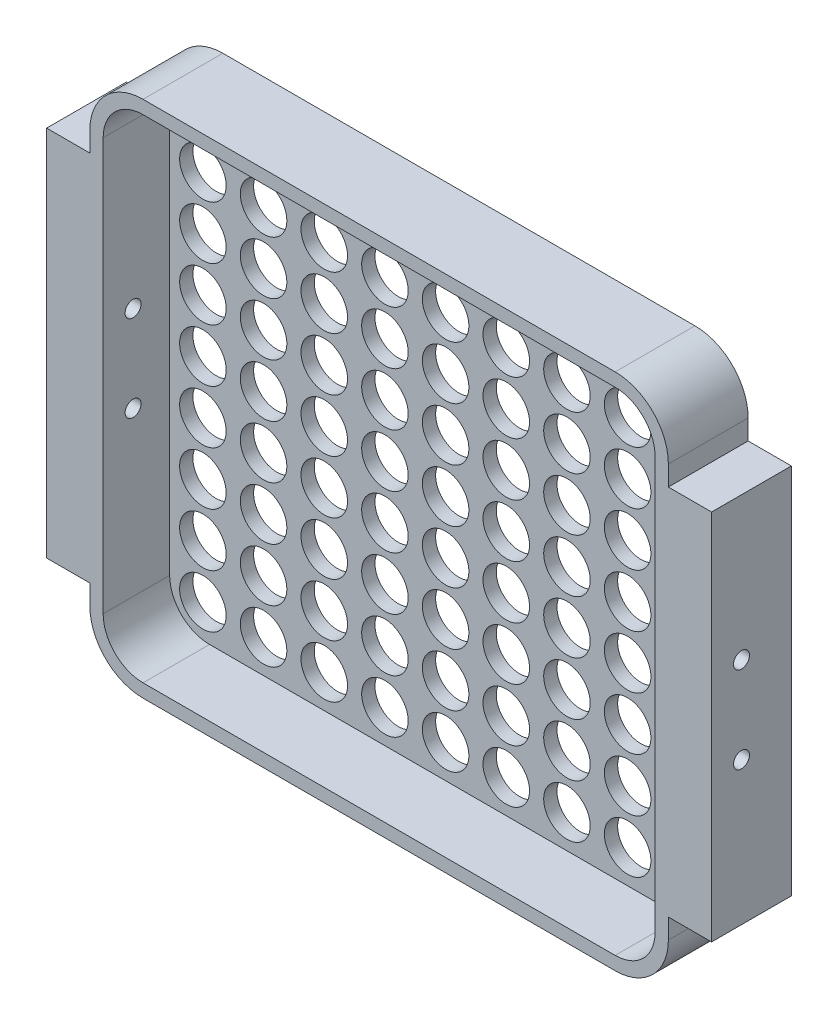
from build123d import *

# Parameters (mm, degrees)
EXTRUDE_THIN1_DEPTH       = 10
BOSS_EXTRUDE1_DEPTH       = 2
SKETCH3_W                 = 3
SKETCH3_H                 = 56
BOSS_EXTRUDE2_DEPTH       = 6.5
SKETCH4_W                 = 9
SKETCH4_H                 = 56
BOSS_EXTRUDE3_DEPTH       = 5
F_3_0MM_DOWEL_HOLE1_D     = 3
F_3_0MM_DOWEL_HOLE1_DEPTH = 150
SKETCH10_R                = 3.5
CUT_EXTRUDE1_DEPTH        = 65.195015383
CUT_EXTRUDE1_DEPTH_BACK   = 65.195015383
BOSS_EXTRUDE4_REACH       = 105.179
SKETCH12_W                = 9
SKETCH12_H                = 56
SKETCH12_R                = 1.5
BOSS_EXTRUDE5_REACH       = 105.179
SKETCH13_W                = 9
SKETCH13_H                = 56
SKETCH13_R                = 1.5
SKETCH14_R                = 1.5
CUT_EXTRUDE2_DEPTH        = 104.179455319
CUT_EXTRUDE2_DEPTH_BACK   = 104.179455319
SKETCH15_R                = 1.5
SKETCH15_R_2              = 1.2
BOSS_EXTRUDE6_DEPTH       = 8.5
BOSS_EXTRUDE7_START       = -100
SKETCH15_2_R              = 1.5
SKETCH15_2_R_2            = 1.2
BOSS_EXTRUDE7_DEPTH       = 8.5


with BuildPart() as part:
    # Sketch1 → Extrude-Thin1 (new body)
    with BuildSketch(Plane.XY):
        with BuildLine():
            Line((-35.5, 39), (35.5, 39))
            ThreePointArc((35.5, 39), (41.156854249, 36.656854249), (43.5, 31))
            Line((43.5, 31), (43.5, -31))
            ThreePointArc((43.5, -31), (41.156854249, -36.656854249), (35.5, -39))
            Line((35.5, -39), (-35.5, -39))
            ThreePointArc((-35.5, -39), (-41.156854249, -36.656854249), (-43.5, -31))
            Line((-43.5, -31), (-43.5, 31))
            ThreePointArc((-43.5, 31), (-41.156854249, 36.656854249), (-35.5, 39))
        make_face()
        with BuildLine():
            Line((-35.5, 37), (35.5, 37))
            ThreePointArc((35.5, 37), (39.742640687, 35.242640687), (41.5, 31))
            Line((41.5, 31), (41.5, -31))
            ThreePointArc((41.5, -31), (39.742640687, -35.242640687), (35.5, -37))
            Line((35.5, -37), (-35.5, -37))
            ThreePointArc((-35.5, -37), (-39.742640687, -35.242640687), (-41.5, -31))
            Line((-41.5, -31), (-41.5, 31))
            ThreePointArc((-41.5, 31), (-39.742640687, 35.242640687), (-35.5, 37))
        make_face(mode=Mode.SUBTRACT)
    extrude(amount=EXTRUDE_THIN1_DEPTH)

    # Sketch2 → Boss-Extrude1 (add)
    with BuildSketch(Plane(origin=(0, 0, 0), x_dir=(-1, 0, 0), z_dir=(0, 0, -1))):
        with BuildLine():
            Line((35.5, 39), (-35.5, 39))
            ThreePointArc((-35.5, 39), (-41.156854249, 36.656854249), (-43.5, 31))
            Line((-43.5, 31), (-43.5, -31))
            ThreePointArc((-43.5, -31), (-41.156854249, -36.656854249), (-35.5, -39))
            Line((-35.5, -39), (35.5, -39))
            ThreePointArc((35.5, -39), (41.156854249, -36.656854249), (43.5, -31))
            Line((43.5, -31), (43.5, 31))
            ThreePointArc((43.5, 31), (41.156854249, 36.656854249), (35.5, 39))
        make_face()
        with BuildLine():
            ThreePointArc((-35.5, -37), (-39.742640687, -35.242640687), (-41.5, -31))
            Line((-41.5, -31), (-41.5, 31))
            ThreePointArc((-41.5, 31), (-39.742640687, 35.242640687), (-35.5, 37))
            Line((-35.5, 37), (35.5, 37))
            ThreePointArc((35.5, 37), (39.742640687, 35.242640687), (41.5, 31))
            Line((41.5, 31), (41.5, -31))
            ThreePointArc((41.5, -31), (39.742640687, -35.242640687), (35.5, -37))
            Line((35.5, -37), (-35.5, -37))
        make_face(mode=Mode.SUBTRACT)
        with BuildLine():
            Line((-41.5, -31), (-41.5, 31))
            ThreePointArc((-41.5, 31), (-39.742640687, 35.242640687), (-35.5, 37))
            Line((-35.5, 37), (35.5, 37))
            ThreePointArc((35.5, 37), (39.742640687, 35.242640687), (41.5, 31))
            Line((41.5, 31), (41.5, -31))
            ThreePointArc((41.5, -31), (39.742640687, -35.242640687), (35.5, -37))
            Line((35.5, -37), (-35.5, -37))
            ThreePointArc((-35.5, -37), (-39.742640687, -35.242640687), (-41.5, -31))
        make_face()
    extrude(amount=BOSS_EXTRUDE1_DEPTH)

    # Sketch3 → Boss-Extrude2 (add)
    with BuildSketch(Plane.ZY.offset(43.5)):
        with Locations((-0.5, 0)):
            Rectangle(SKETCH3_W, SKETCH3_H)
    boss_extrude2 = extrude(amount=BOSS_EXTRUDE2_DEPTH)

    # Sketch4 → Boss-Extrude3 (add)
    with BuildSketch(Plane.ZY.offset(50)):
        with Locations((5.5, 0)):
            Rectangle(SKETCH4_W, SKETCH4_H)
    boss_extrude3 = extrude(amount=-BOSS_EXTRUDE3_DEPTH)

    # Ø3.0mm Dowel Hole1
    with Locations(Plane(origin=(-50, -6.5, 5.5), x_dir=(0, 0, -1), z_dir=(-1, 0, 0))):
        with Locations((0, 0), (0, -13)):
            Hole(F_3_0MM_DOWEL_HOLE1_D / 2, depth=F_3_0MM_DOWEL_HOLE1_DEPTH)

    # Mirror2: Boss-Extrude2, Boss-Extrude3 across plane
    add(boss_extrude2.mirror(Plane(origin=(0, 0, 0), x_dir=(0, 0, 1), z_dir=(1, 0, 0))))
    add(boss_extrude3.mirror(Plane(origin=(0, 0, 0), x_dir=(0, 0, 1), z_dir=(1, 0, 0))))

    # Sketch10 → Cut-Extrude1 (cut, two sides)
    with BuildSketch(Plane.XY) as cut_extrude1_sk:
        with Locations((-27.375, 32)):
            Circle(SKETCH10_R)
        with Locations((-18.25, 32)):
            Circle(SKETCH10_R)
        with Locations((-9.125, 32)):
            Circle(SKETCH10_R)
        with Locations((0, 32)):
            Circle(SKETCH10_R)
        with Locations((-36.5, 32)):
            Circle(SKETCH10_R)
        with Locations((9.125, 32)):
            Circle(SKETCH10_R)
        with Locations((-27.375, 24)):
            Circle(SKETCH10_R)
        with Locations((-18.25, 24)):
            Circle(SKETCH10_R)
        with Locations((-9.125, 24)):
            Circle(SKETCH10_R)
        with Locations((0, 24)):
            Circle(SKETCH10_R)
        with Locations((9.125, 24)):
            Circle(SKETCH10_R)
        with Locations((-27.375, 16)):
            Circle(SKETCH10_R)
        with Locations((-18.25, 16)):
            Circle(SKETCH10_R)
        with Locations((-9.125, 16)):
            Circle(SKETCH10_R)
        with Locations((0, 16)):
            Circle(SKETCH10_R)
        with Locations((9.125, 16)):
            Circle(SKETCH10_R)
        with Locations((-27.375, 8)):
            Circle(SKETCH10_R)
        with Locations((-18.25, 8)):
            Circle(SKETCH10_R)
        with Locations((-9.125, 8)):
            Circle(SKETCH10_R)
        with Locations((0, 8)):
            Circle(SKETCH10_R)
        with Locations((9.125, 8)):
            Circle(SKETCH10_R)
        with Locations((-27.375, 0)):
            Circle(SKETCH10_R)
        with Locations((-18.25, 0)):
            Circle(SKETCH10_R)
        with Locations((-9.125, 0)):
            Circle(SKETCH10_R)
        Circle(SKETCH10_R)
        with Locations((9.125, 0)):
            Circle(SKETCH10_R)
        with Locations((-36.5, 24)):
            Circle(SKETCH10_R)
        with Locations((-36.5, 16)):
            Circle(SKETCH10_R)
        with Locations((-36.5, 8)):
            Circle(SKETCH10_R)
        with Locations((-36.5, 0)):
            Circle(SKETCH10_R)
        with Locations((-36.5, -8)):
            Circle(SKETCH10_R)
        with Locations((-27.375, -8)):
            Circle(SKETCH10_R)
        with Locations((-18.25, -8)):
            Circle(SKETCH10_R)
        with Locations((-9.125, -8)):
            Circle(SKETCH10_R)
        with Locations((0, -8)):
            Circle(SKETCH10_R)
        with Locations((9.125, -8)):
            Circle(SKETCH10_R)
        with Locations((-36.5, -16)):
            Circle(SKETCH10_R)
        with Locations((-27.375, -16)):
            Circle(SKETCH10_R)
        with Locations((-18.25, -16)):
            Circle(SKETCH10_R)
        with Locations((-9.125, -16)):
            Circle(SKETCH10_R)
        with Locations((0, -16)):
            Circle(SKETCH10_R)
        with Locations((9.125, -16)):
            Circle(SKETCH10_R)
        with Locations((-36.5, -24)):
            Circle(SKETCH10_R)
        with Locations((-27.375, -24)):
            Circle(SKETCH10_R)
        with Locations((-18.25, -24)):
            Circle(SKETCH10_R)
        with Locations((-9.125, -24)):
            Circle(SKETCH10_R)
        with Locations((0, -24)):
            Circle(SKETCH10_R)
        with Locations((9.125, -24)):
            Circle(SKETCH10_R)
        with Locations((-36.5, -32)):
            Circle(SKETCH10_R)
        with Locations((-27.375, -32)):
            Circle(SKETCH10_R)
        with Locations((-18.25, -32)):
            Circle(SKETCH10_R)
        with Locations((-9.125, -32)):
            Circle(SKETCH10_R)
        with Locations((0, -32)):
            Circle(SKETCH10_R)
        with Locations((9.125, -32)):
            Circle(SKETCH10_R)
        with Locations((18.25, 32)):
            Circle(SKETCH10_R)
        with Locations((27.375, 32)):
            Circle(SKETCH10_R)
        with Locations((36.5, 32)):
            Circle(SKETCH10_R)
        with Locations((18.25, 24)):
            Circle(SKETCH10_R)
        with Locations((27.375, 24)):
            Circle(SKETCH10_R)
        with Locations((36.5, 24)):
            Circle(SKETCH10_R)
        with Locations((18.25, 16)):
            Circle(SKETCH10_R)
        with Locations((27.375, 16)):
            Circle(SKETCH10_R)
        with Locations((36.5, 16)):
            Circle(SKETCH10_R)
        with Locations((18.25, 8)):
            Circle(SKETCH10_R)
        with Locations((27.375, 8)):
            Circle(SKETCH10_R)
        with Locations((36.5, 8)):
            Circle(SKETCH10_R)
        with Locations((18.25, 0)):
            Circle(SKETCH10_R)
        with Locations((27.375, 0)):
            Circle(SKETCH10_R)
        with Locations((36.5, 0)):
            Circle(SKETCH10_R)
        with Locations((18.25, -8)):
            Circle(SKETCH10_R)
        with Locations((27.375, -8)):
            Circle(SKETCH10_R)
        with Locations((36.5, -8)):
            Circle(SKETCH10_R)
        with Locations((18.25, -16)):
            Circle(SKETCH10_R)
        with Locations((27.375, -16)):
            Circle(SKETCH10_R)
        with Locations((36.5, -16)):
            Circle(SKETCH10_R)
        with Locations((18.25, -24)):
            Circle(SKETCH10_R)
        with Locations((27.375, -24)):
            Circle(SKETCH10_R)
        with Locations((36.5, -24)):
            Circle(SKETCH10_R)
        with Locations((18.25, -32)):
            Circle(SKETCH10_R)
        with Locations((27.375, -32)):
            Circle(SKETCH10_R)
        with Locations((36.5, -32)):
            Circle(SKETCH10_R)
    extrude(amount=CUT_EXTRUDE1_DEPTH, mode=Mode.SUBTRACT)
    extrude(cut_extrude1_sk.sketch, amount=-CUT_EXTRUDE1_DEPTH_BACK, mode=Mode.SUBTRACT)

    # Sketch12 → Boss-Extrude4 (add, up to next)
    with BuildSketch(Plane(origin=(-45, 0, 0), x_dir=(0, 0, -1), z_dir=(1, 0, 0)), mode=Mode.PRIVATE) as boss_extrude4_sk1:
        with Locations((-5.5, 0)):
            Rectangle(SKETCH12_W, SKETCH12_H)
        with Locations(Location((-5.5, 6.5, 0), (0, 0, 180))):
            Circle(SKETCH12_R, mode=Mode.SUBTRACT)
        with Locations(Location((-5.5, -6.5, 0), (0, 0, 180))):
            Circle(SKETCH12_R, mode=Mode.SUBTRACT)
    boss_extrude4_tool1 = extrude(boss_extrude4_sk1.sketch, amount=BOSS_EXTRUDE4_REACH, mode=Mode.PRIVATE) - part.part
    add(boss_extrude4_tool1.solids().sort_by_distance((-45, 0, 5.5))[0])

    # Sketch13 → Boss-Extrude5 (add, up to next)
    with BuildSketch(Plane.ZY.offset(-45), mode=Mode.PRIVATE) as boss_extrude5_sk1:
        with Locations((5.5, 0)):
            Rectangle(SKETCH13_W, SKETCH13_H)
        with Locations((5.5, 6.5)):
            Circle(SKETCH13_R, mode=Mode.SUBTRACT)
        with Locations((5.5, -6.5)):
            Circle(SKETCH13_R, mode=Mode.SUBTRACT)
    boss_extrude5_tool1 = extrude(boss_extrude5_sk1.sketch, amount=BOSS_EXTRUDE5_REACH, mode=Mode.PRIVATE) - part.part
    add(boss_extrude5_tool1.solids().sort_by_distance((45, 0, 5.5))[0])

    # Sketch14 → Cut-Extrude2 (cut, two sides)
    with BuildSketch(Plane.ZY.offset(-45)) as cut_extrude2_sk:
        with Locations((5.5, -6.5)):
            Circle(SKETCH14_R)
        with Locations((5.5, 6.5)):
            Circle(SKETCH14_R)
    extrude(amount=CUT_EXTRUDE2_DEPTH, mode=Mode.SUBTRACT)
    extrude(cut_extrude2_sk.sketch, amount=-CUT_EXTRUDE2_DEPTH_BACK, mode=Mode.SUBTRACT)

    # Sketch15 → Boss-Extrude6 (add)
    with BuildSketch(Plane.ZY.offset(50)):
        with Locations((5.5, 6.5)):
            Circle(SKETCH15_R)
        with Locations((5.5, 6.5)):
            Circle(SKETCH15_R_2, mode=Mode.SUBTRACT)
        with Locations((5.5, -6.5)):
            Circle(SKETCH15_R)
        with Locations((5.5, -6.5)):
            Circle(SKETCH15_R_2, mode=Mode.SUBTRACT)
    extrude(amount=-BOSS_EXTRUDE6_DEPTH)

    # Sketch15_2 → Boss-Extrude7 (add)
    with BuildSketch(Plane.ZY.offset(50).offset(BOSS_EXTRUDE7_START)):
        with Locations((5.5, 6.5)):
            Circle(SKETCH15_2_R)
        with Locations((5.5, 6.5)):
            Circle(SKETCH15_2_R_2, mode=Mode.SUBTRACT)
        with Locations((5.5, -6.5)):
            Circle(SKETCH15_2_R)
        with Locations((5.5, -6.5)):
            Circle(SKETCH15_2_R_2, mode=Mode.SUBTRACT)
    extrude(amount=BOSS_EXTRUDE7_DEPTH)


solid = part.part
